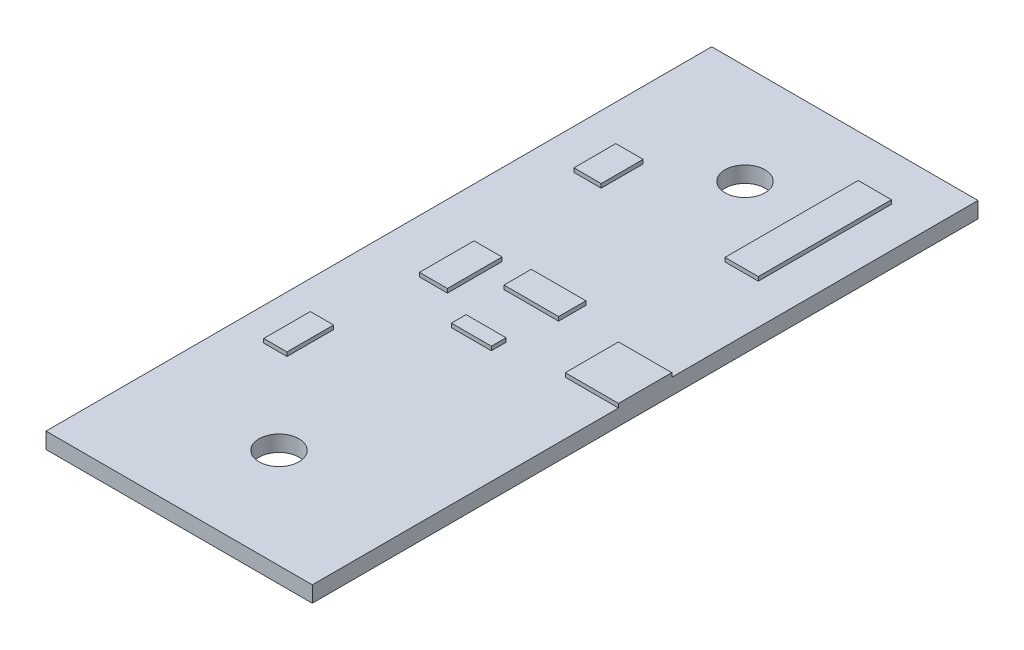
from build123d import *

# Parameters (mm, degrees)
SKETCH1_W           = 20
SKETCH1_H           = 50
BOSS_EXTRUDE1_DEPTH = 1.2
SKETCH2_R           = 1.5
CUT_EXTRUDE1_DEPTH  = 2.2
SKETCH3_W           = 2.5
SKETCH3_H           = 10
SKETCH3_W_2         = 2.05
SKETCH3_H_2         = 3.15
SKETCH3_W_3         = 2.1
SKETCH3_H_3         = 4.1
SKETCH3_W_4         = 4.1
SKETCH3_H_4         = 2.05
SKETCH3_W_5         = 3
SKETCH3_H_5         = 1.1
SKETCH3_W_6         = 4
SKETCH3_H_6         = 4
SKETCH3_W_7         = 1.75
SKETCH3_H_7         = 3.5
BOSS_EXTRUDE2_DEPTH = 1.5


with BuildPart() as part:
    # Sketch1 → Boss-Extrude1 (new body)
    with BuildSketch(Plane(origin=(0, 0, 0), x_dir=(1, 0, 0), z_dir=(0, 1, 0))):
        Rectangle(SKETCH1_W, SKETCH1_H)
    extrude(amount=BOSS_EXTRUDE1_DEPTH)

    # Sketch2 → Cut-Extrude1 (cut, through all)
    with BuildSketch(Plane.XZ):
        with Locations((0, 17.5)):
            Circle(SKETCH2_R)
        with Locations((0, -17.5)):
            Circle(SKETCH2_R)
    extrude(amount=-CUT_EXTRUDE1_DEPTH, mode=Mode.SUBTRACT)

    # Sketch3 → Boss-Extrude2 (add)
    with BuildSketch(Plane.XZ):
        with Locations((5.75, -16.5)):
            Rectangle(SKETCH3_W, SKETCH3_H)
        with Locations((-5.975, -13.225)):
            Rectangle(SKETCH3_W_2, SKETCH3_H_2)
        with Locations((-4.95, -1.1)):
            Rectangle(SKETCH3_W_3, SKETCH3_H_3)
        with Locations((0.05, -2.425)):
            Rectangle(SKETCH3_W_4, SKETCH3_H_4)
        with Locations((0, 2.5)):
            Rectangle(SKETCH3_W_5, SKETCH3_H_5)
        with Locations((8, 0)):
            Rectangle(SKETCH3_W_6, SKETCH3_H_6)
        with Locations((-6.675, 9.35)):
            Rectangle(SKETCH3_W_7, SKETCH3_H_7)
    extrude(amount=-BOSS_EXTRUDE2_DEPTH)


solid = part.part
